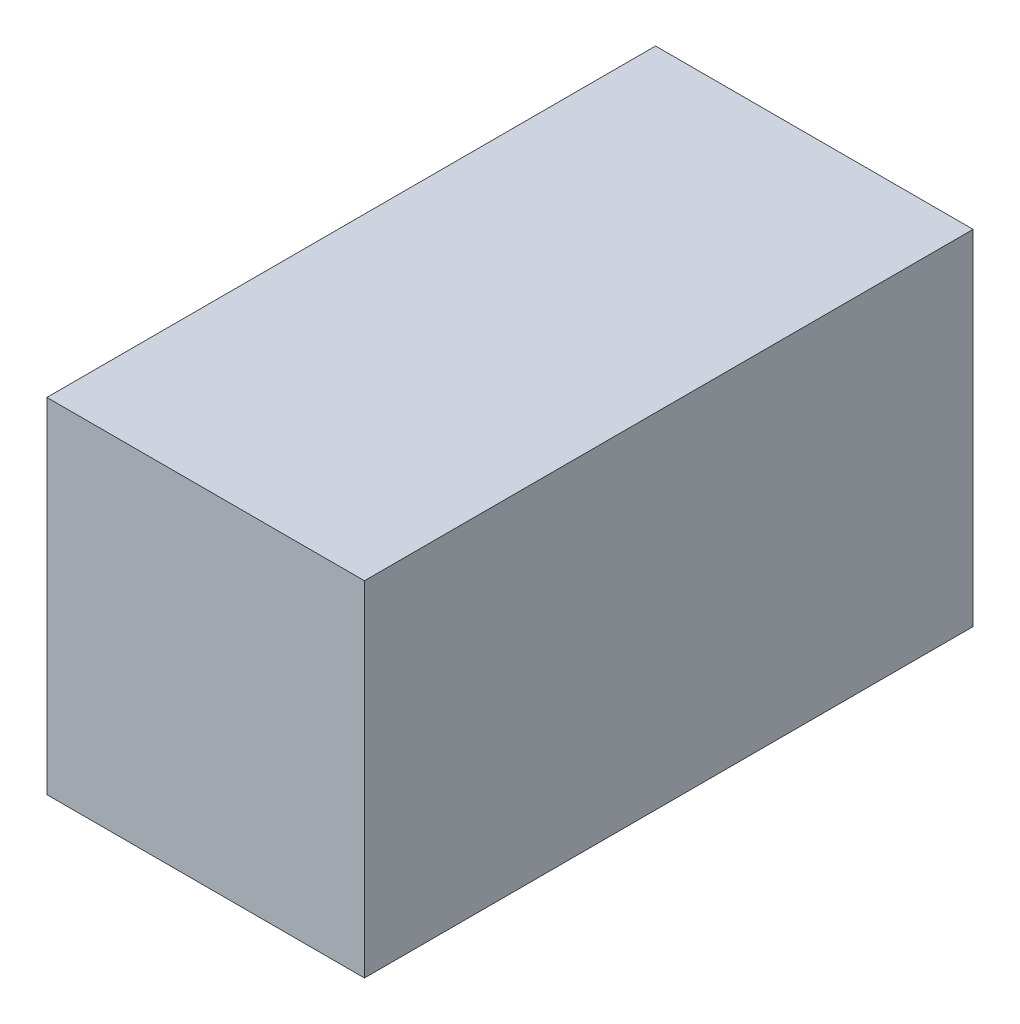
from build123d import *

# Parameters (mm, degrees)
SKETCH1_W           = 24
SKETCH1_H           = 46
BOSS_EXTRUDE1_DEPTH = 26


with BuildPart() as part:
    # Sketch1 → Boss-Extrude1 (new body)
    with BuildSketch(Plane(origin=(0, 0, 0), x_dir=(1, 0, 0), z_dir=(0, 1, 0))):
        Rectangle(SKETCH1_W, SKETCH1_H)
    extrude(amount=BOSS_EXTRUDE1_DEPTH)


solid = part.part
